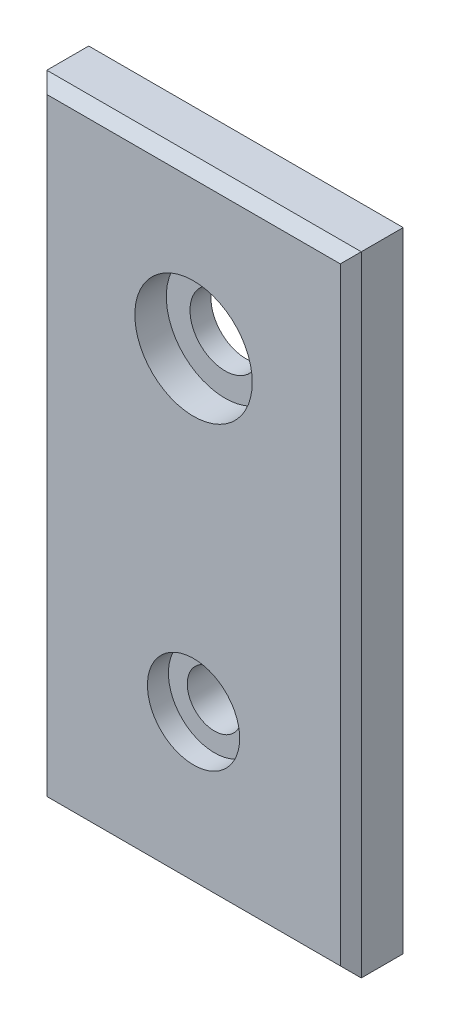
from build123d import *

# Parameters (mm, degrees)
SKETCH1_W           = 38.1
SKETCH1_H           = 76.2
BOSS_EXTRUDE1_DEPTH = 6.35
SKETCH2_R           = 4.2418
SKETCH2_R_2         = 3.302
CUT_EXTRUDE1_DEPTH  = 6.35
CHAMFER1_SIZE       = 1.27
SKETCH4_R           = 5.588
CUT_EXTRUDE2_DEPTH  = 2.54
SKETCH3_R           = 7.112
CUT_EXTRUDE3_DEPTH  = 3.81


with BuildPart() as part:
    # Sketch1 → Boss-Extrude1 (new body)
    with BuildSketch(Plane.XY):
        with Locations((31.774534541, 118.99557006)):
            Rectangle(SKETCH1_W, SKETCH1_H)
    extrude(amount=BOSS_EXTRUDE1_DEPTH)

    # Sketch2 → Cut-Extrude1 (cut)
    with BuildSketch(Plane.XY.offset(6.35)):
        with Locations((31.774534541, 138.04557006)):
            Circle(SKETCH2_R)
        with Locations((31.774534541, 99.94557006)):
            Circle(SKETCH2_R_2)
    extrude(amount=-CUT_EXTRUDE1_DEPTH, mode=Mode.SUBTRACT)

    # Chamfer1
    chamfer1_edges = [part.edges().sort_by_distance(p)[0] for p in [
        (50.824534541, 118.99557006, 6.35),
        (31.774534541, 157.09557006, 6.35),
        (12.724534541, 118.99557006, 6.35),
        (31.774534541, 80.89557006, 6.35),
    ]]
    chamfer(chamfer1_edges, length=CHAMFER1_SIZE)

    # Sketch4 → Cut-Extrude2 (cut)
    with BuildSketch(Plane.XY.offset(6.35)):
        with Locations((31.774534541, 99.94557006)):
            Circle(SKETCH4_R)
    extrude(amount=-CUT_EXTRUDE2_DEPTH, mode=Mode.SUBTRACT)

    # Sketch3 → Cut-Extrude3 (cut)
    with BuildSketch(Plane.XY.offset(6.35)):
        with Locations((31.774534541, 138.04557006)):
            Circle(SKETCH3_R)
    extrude(amount=-CUT_EXTRUDE3_DEPTH, mode=Mode.SUBTRACT)


solid = part.part
